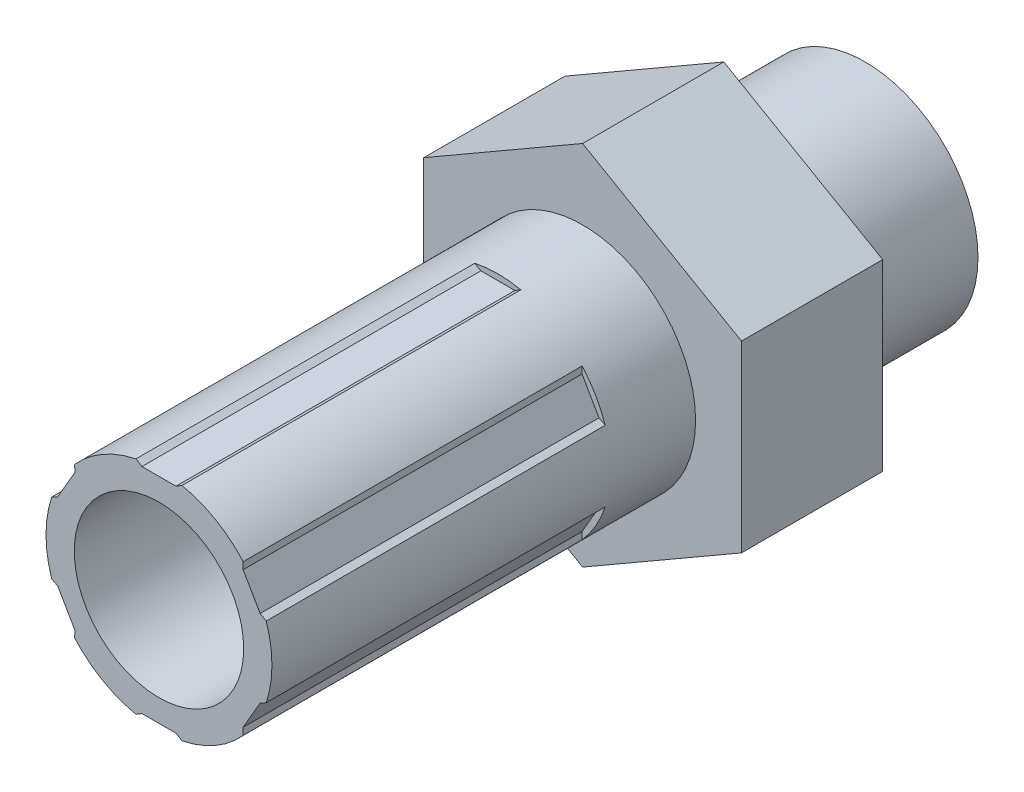
from build123d import *

# Parameters (mm, degrees)
BOSS_EXTRUDE1_DEPTH = 6.35
SKETCH2_R           = 5.08
BOSS_EXTRUDE2_DEPTH = 6.35
SKETCH3_R           = 5.08
BOSS_EXTRUDE3_DEPTH = 19.05
SKETCH4_R           = 3.81
CUT_EXTRUDE1_DEPTH  = 32.75
CUT_EXTRUDE2_DEPTH  = 15.24
CIRPATTERN1_COUNT   = 6


with BuildPart() as part:
    # Sketch1 → Boss-Extrude1 (new body)
    with BuildSketch(Plane.XY):
        Polygon((0, 8.248891971), (-7.14375, 4.124445986), (-7.14375, -4.124445986), (0, -8.248891971), (7.14375, -4.124445986), (7.14375, 4.124445986), align=None)
    extrude(amount=BOSS_EXTRUDE1_DEPTH)

    # Sketch2 → Boss-Extrude2 (add)
    with BuildSketch(Plane(origin=(0, 0, 0), x_dir=(-1, 0, 0), z_dir=(0, 0, -1))):
        Circle(SKETCH2_R)
    extrude(amount=BOSS_EXTRUDE2_DEPTH)

    # Sketch3 → Boss-Extrude3 (add)
    with BuildSketch(Plane.XY.offset(6.35)):
        Circle(SKETCH3_R)
    extrude(amount=BOSS_EXTRUDE3_DEPTH)

    # Sketch4 → Cut-Extrude1 (cut, through all)
    with BuildSketch(Plane.XY.offset(25.4)):
        Circle(SKETCH4_R)
    extrude(amount=-CUT_EXTRUDE1_DEPTH, mode=Mode.SUBTRACT)

    # Sketch5 → Cut-Extrude2 (cut)
    with BuildSketch(Plane.XY.offset(25.4)):
        Polygon((0, 4.810914796), (0.765045953, 4.810914796), (1.27, 5.114868927), (0, 5.114868927), (-1.27, 5.114868927), (-0.765045953, 4.810914796), align=None)
    cut_extrude2 = extrude(amount=-CUT_EXTRUDE2_DEPTH, mode=Mode.SUBTRACT)

    # CirPattern1: Cut-Extrude2 ×6 about axis
    cirpattern1_axis = Axis((0, 0, 0), (0, 0, 1))
    for i in range(1, CIRPATTERN1_COUNT):
        add(cut_extrude2.rotate(cirpattern1_axis, i * 360 / CIRPATTERN1_COUNT), mode=Mode.SUBTRACT)


solid = part.part
